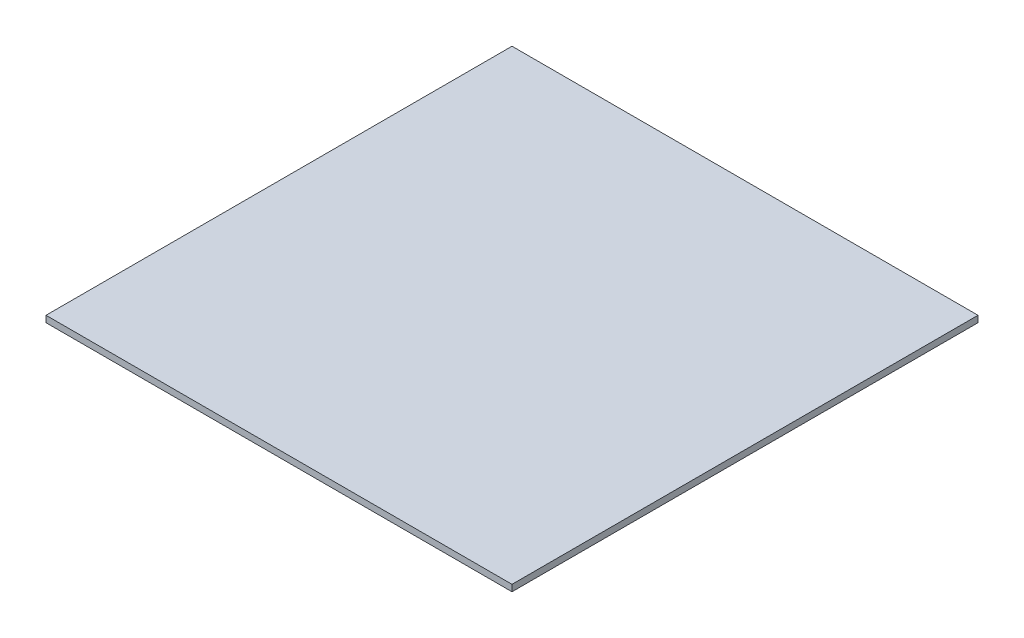
from build123d import *

# Parameters (mm, degrees)
SKETCH1_W           = 914.4
SKETCH1_H           = 914.4
BOSS_EXTRUDE1_DEPTH = 12.7


with BuildPart() as part:
    # Sketch1 → Boss-Extrude1 (new body)
    with BuildSketch(Plane(origin=(0, 0, 0), x_dir=(1, 0, 0), z_dir=(0, 1, 0))):
        with Locations((457.2, 457.2)):
            Rectangle(SKETCH1_W, SKETCH1_H)
    extrude(amount=BOSS_EXTRUDE1_DEPTH)


solid = part.part
